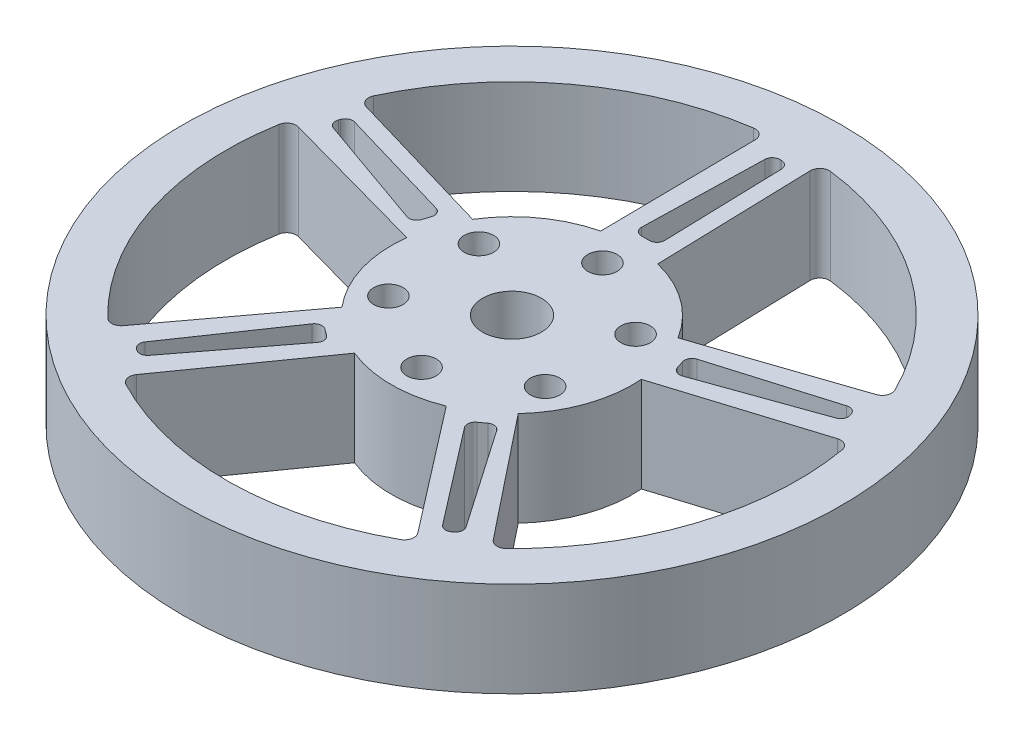
from build123d import *

# Parameters (mm, degrees)
SKETCH1_R           = 34.7
SKETCH1_R_2         = 1.55
SKETCH1_R_3         = 3.1
BOSS_EXTRUDE1_DEPTH = 10
FILLET2_R           = 1
FILLET3_R           = 0.8


with BuildPart() as part:
    # Sketch1 → Boss-Extrude1 (new body)
    with BuildSketch(Plane(origin=(0, 0, 0), x_dir=(1, 0, 0), z_dir=(0, 1, 0))):
        with Locations((0, -6.629356842)):
            Circle(SKETCH1_R)
        with Locations((0, 2.895643158)):
            Circle(SKETCH1_R_2, mode=Mode.SUBTRACT)
        with Locations((-8.248891971, -1.866856842)):
            Circle(SKETCH1_R_2, mode=Mode.SUBTRACT)
        with Locations((-8.248891971, -11.391856842)):
            Circle(SKETCH1_R_2, mode=Mode.SUBTRACT)
        with Locations((0, -16.154356842)):
            Circle(SKETCH1_R_2, mode=Mode.SUBTRACT)
        with Locations((8.248891971, -1.866856842)):
            Circle(SKETCH1_R_2, mode=Mode.SUBTRACT)
        with Locations((0, -6.629356842)):
            Circle(SKETCH1_R_3, mode=Mode.SUBTRACT)
        with Locations((8.248891971, -11.391856842)):
            Circle(SKETCH1_R_2, mode=Mode.SUBTRACT)
        with BuildLine():
            Line((-3.20212766, 23.299832563), (-3, 5.711226612))
            ThreePointArc((-3, 5.711226612), (-7.464872704, 3.645158986), (-10.809541326, 0.037262715))
            Line((-10.809541326, 0.037262715), (-27.755348523, 5.017558129))
            ThreePointArc((-27.755348523, 5.017558129), (-17.976421293, 17.513101141), (-3.20212766, 23.299832563))
        make_face(mode=Mode.SUBTRACT)
        with BuildLine():
            Line((2.5, 23.366642891), (3, 5.711226612))
            ThreePointArc((3, 5.711226612), (7.464872704, 3.645158986), (10.809541326, 0.037262715))
            Line((10.809541326, 0.037262715), (27.474838746, 5.664675689))
            ThreePointArc((27.474838746, 5.664675689), (17.405822307, 17.927665571), (2.5, 23.366642891))
        make_face(mode=Mode.SUBTRACT)
        Polygon((-0.875343089, 21.666642891), (0.847462288, 21.666642891), (1.251174555, 7.411226612), (-1.221162893, 7.411226612), align=None, mode=Mode.SUBTRACT)
        Polygon((12.9760283, -1.129183017), (26.640599041, 2.947088697), (27.17297518, 1.308603417), (13.740022588, -3.480515657), align=None, mode=Mode.SUBTRACT)
        with BuildLine():
            Line((29.453862476, -0.426133065), (12.663643293, -5.669076383))
            ThreePointArc((12.663643293, -5.669076383), (11.986909153, -10.825070007), (9.300423223, -15.27760105))
            Line((9.300423223, -15.27760105), (20.18251184, -28.960416285))
            ThreePointArc((20.18251184, -28.960416285), (28.62680114, -15.930768373), (29.453862476, -0.426133065))
        make_face(mode=Mode.SUBTRACT)
        Polygon((9.240789422, -17.270645929), (17.340138777, -29.006787741), (15.946359949, -30.019427334), (7.24062641, -18.723849419), align=None, mode=Mode.SUBTRACT)
        with BuildLine():
            Line((15.608663785, -32.36609352), (4.826561976, -18.376454334))
            ThreePointArc((4.826561976, -18.376454334), (0, -19.329356842), (-4.826561976, -18.376454334))
            Line((-4.826561976, -18.376454334), (-15.001360451, -32.724743113))
            ThreePointArc((-15.001360451, -32.724743113), (0.352649568, -36.727290962), (15.608663785, -32.36609352))
        make_face(mode=Mode.SUBTRACT)
        Polygon((-7.264906355, -18.706209007), (-15.923803908, -30.035815257), (-17.317582735, -29.023175665), (-9.265069366, -17.253005516), align=None, mode=Mode.SUBTRACT)
        with BuildLine():
            Line((-20.18251184, -28.960416285), (-9.680663942, -14.849742821))
            ThreePointArc((-9.680663942, -14.849742821), (-12.163791536, -10.280682009), (-12.607510846, -5.099431917))
            Line((-12.607510846, -5.099431917), (-29.453862476, -0.426133065))
            ThreePointArc((-29.453862476, -0.426133065), (-28.62680114, -15.930768373), (-20.18251184, -28.960416285))
        make_face(mode=Mode.SUBTRACT)
        Polygon((-13.730748474, -3.451972871), (-27.181590822, 1.2820872), (-26.649214682, 2.920572479), (-12.966754187, -1.10064023), align=None, mode=Mode.SUBTRACT)
    extrude(amount=BOSS_EXTRUDE1_DEPTH)

    # Fillet2
    fillet2_edges = [part.edges().sort_by_distance(p)[0] for p in [
        (15.608663785, 5, 32.36609352),
        (-29.453862476, 5, 0.426133065),
        (-20.18251184, 5, 28.960416285),
        (27.474838746, 5, -5.664675689),
        (2.5, 5, -23.366642891),
        (-3.20212766, 5, -23.299832563),
        (-27.755348523, 5, -5.017558129),
        (20.18251184, 5, 28.960416285),
        (29.453862476, 5, 0.426133065),
        (-15.001360451, 5, 32.724743113),
    ]]
    fillet(fillet2_edges, radius=FILLET2_R)

    # Fillet3
    fillet3_edges = [part.edges().sort_by_distance(p)[0] for p in [
        (15.946359949, 5, 30.019427334),
        (17.340138777, 5, 29.006787741),
        (9.240789422, 5, 17.270645929),
        (7.24062641, 5, 18.723849419),
        (-17.317582735, 5, 29.023175665),
        (-15.923803908, 5, 30.035815257),
        (-7.264906355, 5, 18.706209007),
        (-9.265069366, 5, 17.253005516),
        (-26.649214682, 5, -2.920572479),
        (-27.181590822, 5, -1.2820872),
        (-13.730748474, 5, 3.451972871),
        (-12.966754187, 5, 1.10064023),
        (-0.875343089, 5, -21.666642891),
        (-1.221162893, 5, -7.411226612),
        (1.251174555, 5, -7.411226612),
        (0.847462288, 5, -21.666642891),
        (27.17297518, 5, -1.308603417),
        (26.640599041, 5, -2.947088697),
        (12.9760283, 5, 1.129183017),
        (13.740022588, 5, 3.480515657),
    ]]
    fillet(fillet3_edges, radius=FILLET3_R)


solid = part.part
